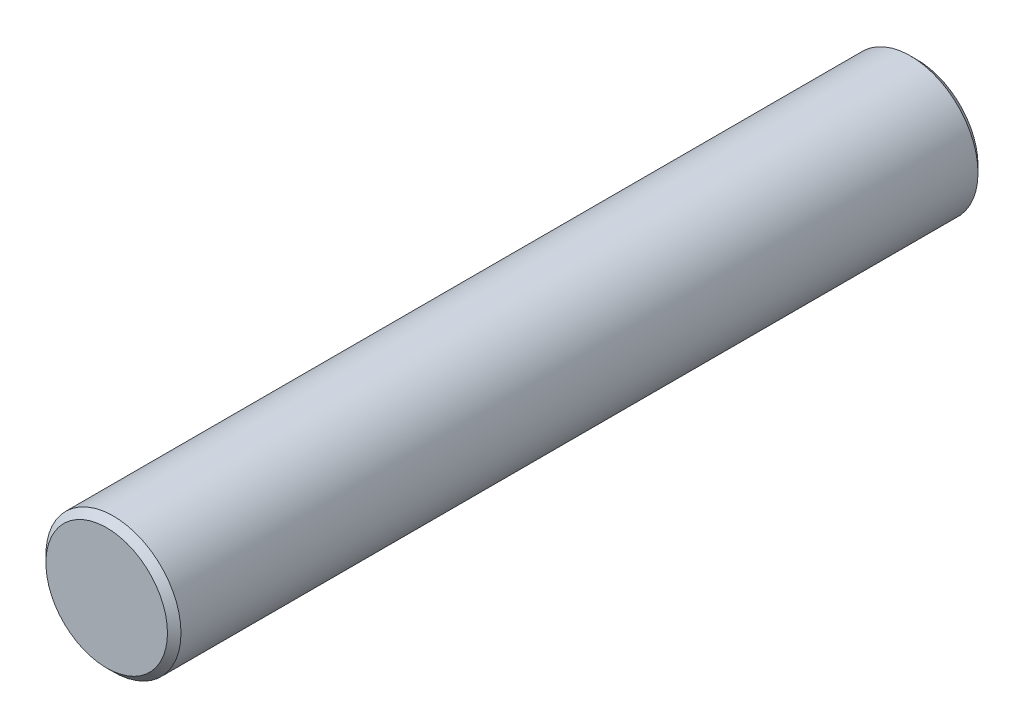
from build123d import *

# Parameters (mm, degrees)
SKETCH1_R           = 1
BOSS_EXTRUDE1_DEPTH = 12
CHAMFER1_SIZE       = 0.1


with BuildPart() as part:
    # Sketch1 → Boss-Extrude1 (new body)
    with BuildSketch(Plane.XY):
        Circle(SKETCH1_R)
    extrude(amount=BOSS_EXTRUDE1_DEPTH)

    # Chamfer1
    chamfer1_edges = [part.edges().sort_by_distance(p)[0] for p in [
        (-1, 0, 0),
        (-1, 0, 12),
    ]]
    chamfer(chamfer1_edges, length=CHAMFER1_SIZE)


solid = part.part
